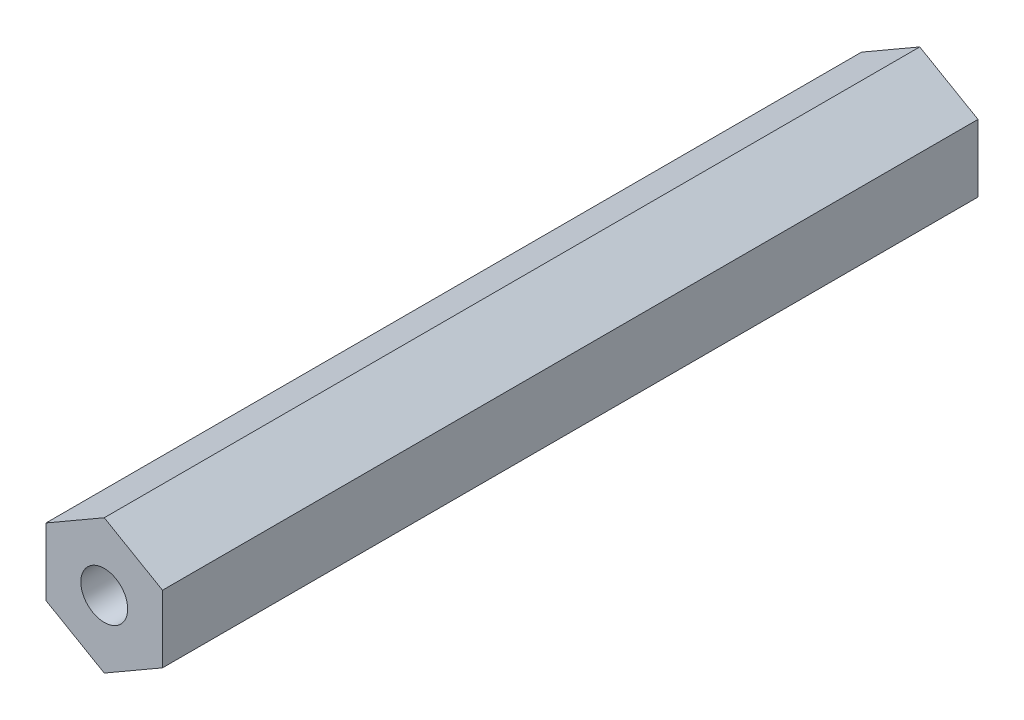
from build123d import *

# Parameters (mm, degrees)
BOSS_EXTRUDE1_DEPTH         = 88.9
F_1_4_20_TAPPED_HOLE1_D     = 5.1054
F_1_4_20_TAPPED_HOLE1_DEPTH = 16.51
F_1_4_20_TAPPED_HOLE1_TIP   = 1.533816902
F_1_4_20_TAPPED_HOLE2_D     = 5.1054
F_1_4_20_TAPPED_HOLE2_DEPTH = 16.51
F_1_4_20_TAPPED_HOLE2_TIP   = 1.533816902


with BuildPart() as part:
    # Sketch1 → Boss-Extrude1 (new body)
    with BuildSketch(Plane.XY):
        Polygon((6.35, 3.666174209), (0, 7.332348419), (-6.35, 3.666174209), (-6.35, -3.666174209), (0, -7.332348419), (6.35, -3.666174209), align=None)
    extrude(amount=BOSS_EXTRUDE1_DEPTH)

    # 1/4-20 Tapped Hole1
    with Locations(Plane.XY.offset(88.9)):
        with Locations((0, 0)):
            Hole(F_1_4_20_TAPPED_HOLE1_D / 2, depth=F_1_4_20_TAPPED_HOLE1_DEPTH)
            with Locations((0, 0, -(F_1_4_20_TAPPED_HOLE1_DEPTH + F_1_4_20_TAPPED_HOLE1_TIP / 2))):  # 118° drill point
                Cone(0, F_1_4_20_TAPPED_HOLE1_D / 2, F_1_4_20_TAPPED_HOLE1_TIP, mode=Mode.SUBTRACT)

    # 1/4-20 Tapped Hole2
    with Locations(Plane(origin=(0, 0, 0), x_dir=(-1, 0, 0), z_dir=(0, 0, -1))):
        with Locations((0, 0)):
            Hole(F_1_4_20_TAPPED_HOLE2_D / 2, depth=F_1_4_20_TAPPED_HOLE2_DEPTH)
            with Locations((0, 0, -(F_1_4_20_TAPPED_HOLE2_DEPTH + F_1_4_20_TAPPED_HOLE2_TIP / 2))):  # 118° drill point
                Cone(0, F_1_4_20_TAPPED_HOLE2_D / 2, F_1_4_20_TAPPED_HOLE2_TIP, mode=Mode.SUBTRACT)


solid = part.part
